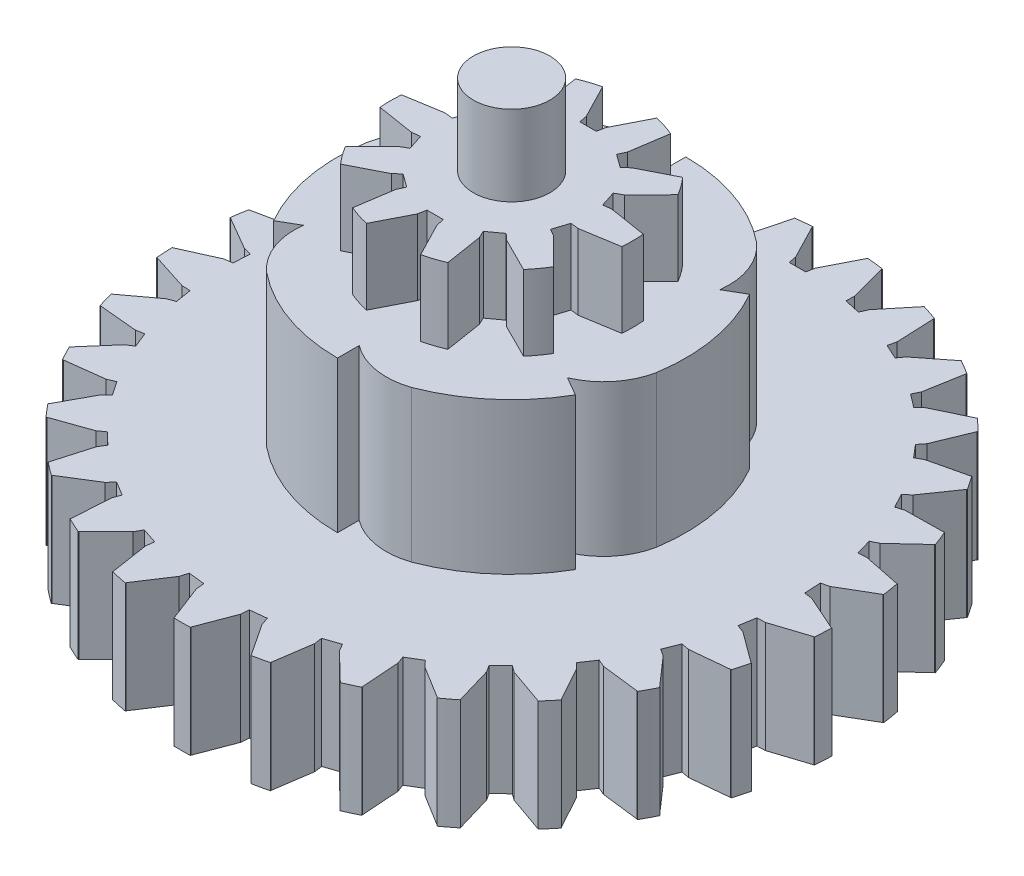
from build123d import *

# Parameters (mm, degrees)
SKETCH1_R           = 4.5085
BOSS_EXTRUDE1_DEPTH = 2.794
SKETCH2_R           = 1.4224
BOSS_EXTRUDE2_DEPTH = 2.9845
CUT_EXTRUDE1_DEPTH  = 3.794
SKETCH4_R           = 6.477
BOSS_EXTRUDE3_DEPTH = 5.6261
CUT_EXTRUDE2_DEPTH  = 6.6261
SKETCH6_R           = 12.26185
BOSS_EXTRUDE4_DEPTH = 4.1275
SKETCH7_R           = 1.4224
BOSS_EXTRUDE5_DEPTH = 3.302
CUT_EXTRUDE4_START  = -8.4295
CUT_EXTRUDE4_DEPTH  = 20.8341
CIRPATTERN3_COUNT   = 29


with BuildPart() as part:
    # Sketch1 → Boss-Extrude1 (new body)
    with BuildSketch(Plane(origin=(0, 0, 0), x_dir=(1, 0, 0), z_dir=(0, 1, 0))):
        with Locations((-83.120700882, 52.732487656)):
            Circle(SKETCH1_R)
    extrude(amount=BOSS_EXTRUDE1_DEPTH)

    # Sketch2 → Boss-Extrude2 (add)
    with BuildSketch(Plane(origin=(0, 2.794, 0), x_dir=(1, 0, 0), z_dir=(0, 1, 0))):
        with Locations((-83.120700882, 52.732487656)):
            Circle(SKETCH2_R)
    extrude(amount=BOSS_EXTRUDE2_DEPTH)

    # Sketch3 → Cut-Extrude1 (cut, through all)
    with BuildSketch(Plane(origin=(0, 2.794, 0), x_dir=(1, 0, 0), z_dir=(0, 1, 0))):
        with BuildLine():
            Line((-84.673607873, 55.488015957), (-84.892824637, 56.878105782))
            ThreePointArc((-84.892824637, 56.878105782), (-85.774201932, 56.377416246), (-86.521443741, 55.692474186))
            Line((-86.521443741, 55.692474186), (-85.261813421, 55.05922157))
            Line((-85.261813421, 55.05922157), (-85.037775379, 54.852557602))
            Line((-85.037775379, 54.852557602), (-84.791186999, 55.031714547))
            Line((-84.791186999, 55.031714547), (-84.544598619, 55.210871492))
            Line((-84.544598619, 55.210871492), (-84.673607873, 55.488015957))
        make_face()
        with BuildLine():
            Line((-83.120700882, 57.240987656), (-83.120700882, 55.574488389))
            Line((-83.120700882, 55.574488389), (-82.815900882, 55.574488389))
            Line((-82.815900882, 55.574488389), (-82.757370131, 55.874532708))
            Line((-82.757370131, 55.874532708), (-82.11764592, 57.127991381))
            ThreePointArc((-82.11764592, 57.127991381), (-82.616001116, 57.212649528), (-83.120700882, 57.240987656))
        make_face()
        with BuildLine():
            Line((-83.425500882, 55.574488389), (-83.120700882, 55.574488389))
            Line((-83.120700882, 55.574488389), (-83.120700882, 57.240987656))
            ThreePointArc((-83.120700882, 57.240987656), (-83.629665614, 57.212167014), (-84.132123219, 57.126073561))
            Line((-84.132123219, 57.126073561), (-83.485277432, 55.873369308))
            Line((-83.485277432, 55.873369308), (-83.425500882, 55.574488389))
        make_face()
        with BuildLine():
            ThreePointArc((-79.725600106, 55.698943954), (-80.474144714, 56.382461998), (-81.356473741, 56.881472453))
            Line((-81.356473741, 56.881472453), (-81.569485593, 55.487807009))
            Line((-81.569485593, 55.487807009), (-81.696803144, 55.210871492))
            Line((-81.696803144, 55.210871492), (-81.450214764, 55.031714547))
            Line((-81.450214764, 55.031714547), (-81.203626384, 54.852557602))
            Line((-81.203626384, 54.852557602), (-80.979912387, 55.060895043))
            Line((-80.979912387, 55.060895043), (-79.725600106, 55.698943954))
        make_face()
        with BuildLine():
            ThreePointArc((-78.630367393, 53.136811048), (-78.834190876, 54.129772243), (-79.254699067, 55.052100171))
            Line((-79.254699067, 55.052100171), (-80.24620527, 54.049806368))
            Line((-80.24620527, 54.049806368), (-80.511985946, 53.900596207))
            Line((-80.511985946, 53.900596207), (-80.417797566, 53.610714181))
            Line((-80.417797566, 53.610714181), (-80.323609186, 53.320832154))
            Line((-80.323609186, 53.320832154), (-80.020163085, 53.357884896))
            Line((-80.020163085, 53.357884896), (-78.630367393, 53.136811048))
        make_face()
        with BuildLine():
            ThreePointArc((-79.250289452, 50.420240349), (-78.831538167, 51.343367268), (-78.629605686, 52.33671475))
            Line((-78.629605686, 52.33671475), (-80.02088457, 52.108634752))
            Line((-80.02088457, 52.108634752), (-80.323609186, 52.144143158))
            Line((-80.323609186, 52.144143158), (-80.417797566, 51.854261132))
            Line((-80.417797566, 51.854261132), (-80.511985946, 51.564379106))
            Line((-80.511985946, 51.564379106), (-80.244713838, 51.41599426))
            Line((-80.244713838, 51.41599426), (-79.250289452, 50.420240349))
        make_face()
        with BuildLine():
            ThreePointArc((-81.348577127, 48.58686953), (-80.467199832, 49.087559066), (-79.719958023, 49.772501126))
            Line((-79.719958023, 49.772501126), (-80.979588343, 50.405753742))
            Line((-80.979588343, 50.405753742), (-81.203626384, 50.612417711))
            Line((-81.203626384, 50.612417711), (-81.450214764, 50.433260766))
            Line((-81.450214764, 50.433260766), (-81.696803144, 50.254103821))
            Line((-81.696803144, 50.254103821), (-81.56779389, 49.976959356))
            Line((-81.56779389, 49.976959356), (-81.348577127, 48.58686953))
        make_face()
        with BuildLine():
            Line((-83.484031632, 49.590442605), (-84.123755844, 48.336983932))
            ThreePointArc((-84.123755844, 48.336983932), (-83.116408709, 48.223989699), (-82.109278545, 48.338901751))
            Line((-82.109278545, 48.338901751), (-82.756124332, 49.591606004))
            Line((-82.756124332, 49.591606004), (-82.815900882, 49.890486924))
            Line((-82.815900882, 49.890486924), (-83.120700882, 49.890486924))
            Line((-83.120700882, 49.890486924), (-83.425500882, 49.890486924))
            Line((-83.425500882, 49.890486924), (-83.484031632, 49.590442605))
        make_face()
        with BuildLine():
            Line((-85.261489377, 50.40408027), (-86.515801658, 49.766031358))
            ThreePointArc((-86.515801658, 49.766031358), (-85.76725705, 49.082513314), (-84.884928023, 48.583502859))
            Line((-84.884928023, 48.583502859), (-84.671916171, 49.977168303))
            Line((-84.671916171, 49.977168303), (-84.544598619, 50.254103821))
            Line((-84.544598619, 50.254103821), (-84.791186999, 50.433260766))
            Line((-84.791186999, 50.433260766), (-85.037775379, 50.612417711))
            Line((-85.037775379, 50.612417711), (-85.261489377, 50.40408027))
        make_face()
        with BuildLine():
            Line((-86.221238679, 52.107090416), (-87.611034371, 52.328164264))
            ThreePointArc((-87.611034371, 52.328164264), (-87.407210888, 51.335203069), (-86.986702696, 50.412875141))
            Line((-86.986702696, 50.412875141), (-85.995196494, 51.415168945))
            Line((-85.995196494, 51.415168945), (-85.729415818, 51.564379106))
            Line((-85.729415818, 51.564379106), (-85.823604198, 51.854261132))
            Line((-85.823604198, 51.854261132), (-85.917792578, 52.144143158))
            Line((-85.917792578, 52.144143158), (-86.221238679, 52.107090416))
        make_face()
        with BuildLine():
            Line((-85.996687926, 54.048981052), (-86.991112312, 55.044734964))
            ThreePointArc((-86.991112312, 55.044734964), (-87.409863597, 54.121608045), (-87.611796077, 53.128260563))
            Line((-87.611796077, 53.128260563), (-86.220517194, 53.35634056))
            Line((-86.220517194, 53.35634056), (-85.917792578, 53.320832154))
            Line((-85.917792578, 53.320832154), (-85.823604198, 53.610714181))
            Line((-85.823604198, 53.610714181), (-85.729415818, 53.900596207))
            Line((-85.729415818, 53.900596207), (-85.996687926, 54.048981052))
        make_face()
    extrude(amount=-CUT_EXTRUDE1_DEPTH, mode=Mode.SUBTRACT)

    # Sketch4 → Boss-Extrude3 (add)
    with BuildSketch(Plane.XZ):
        with Locations((-83.120700882, -52.732487656)):
            Circle(SKETCH4_R)
    extrude(amount=BOSS_EXTRUDE3_DEPTH)

    # Sketch5 → Cut-Extrude2 (cut, through all)
    with BuildSketch(Plane(origin=(0, 0, 0), x_dir=(1, 0, 0), z_dir=(0, 1, 0))):
        with BuildLine():
            Line((-83.120700882, 58.401482942), (-83.120700882, 59.209487656))
            ThreePointArc((-83.120700882, 59.209487656), (-84.304718474, 59.100346899), (-85.448833465, 58.776602784))
            ThreePointArc((-85.448833465, 58.776602784), (-84.238083312, 58.878780186), (-83.120700882, 58.401482942))
        make_face()
        with BuildLine():
            Line((-78.21120695, 55.566985299), (-77.511454342, 55.970987656))
            ThreePointArc((-77.511454342, 55.970987656), (-78.197981806, 56.941806591), (-79.05040993, 57.77076718))
            ThreePointArc((-79.05040993, 57.77076718), (-78.356546627, 56.773315492), (-78.21120695, 55.566985299))
        make_face()
        with BuildLine():
            Line((-78.21120695, 49.897990013), (-77.511454342, 49.493987656))
            ThreePointArc((-77.511454342, 49.493987656), (-77.013964213, 50.573947348), (-76.722277346, 51.726652053))
            ThreePointArc((-76.722277346, 51.726652053), (-77.239164197, 50.627022962), (-78.21120695, 49.897990013))
        make_face()
        with BuildLine():
            Line((-83.120700882, 47.06349237), (-83.120700882, 46.255487656))
            ThreePointArc((-83.120700882, 46.255487656), (-81.936683289, 46.364628413), (-80.792568299, 46.688372529))
            ThreePointArc((-80.792568299, 46.688372529), (-82.003318452, 46.586195126), (-83.120700882, 47.06349237))
        make_face()
        with BuildLine():
            Line((-88.030194814, 49.897990013), (-88.729947422, 49.493987656))
            ThreePointArc((-88.729947422, 49.493987656), (-88.043419958, 48.523168721), (-87.190991834, 47.694208132))
            ThreePointArc((-87.190991834, 47.694208132), (-87.884855137, 48.691659821), (-88.030194814, 49.897990013))
        make_face()
        with BuildLine():
            Line((-88.030194814, 55.566985299), (-88.729947422, 55.970987656))
            ThreePointArc((-88.729947422, 55.970987656), (-89.22743755, 54.891027964), (-89.519124417, 53.73832326))
            ThreePointArc((-89.519124417, 53.73832326), (-89.002237567, 54.837952351), (-88.030194814, 55.566985299))
        make_face()
    extrude(amount=-CUT_EXTRUDE2_DEPTH, mode=Mode.SUBTRACT)

    # Sketch6 → Boss-Extrude4 (add)
    with BuildSketch(Plane.XZ.offset(5.6261)):
        with Locations((-83.120700882, -52.732487656)):
            Circle(SKETCH6_R)
    extrude(amount=BOSS_EXTRUDE4_DEPTH)

    # Sketch7 → Boss-Extrude5 (add)
    with BuildSketch(Plane.XZ.offset(9.7536)):
        with Locations((-83.120700882, -52.732487656)):
            Circle(SKETCH7_R)
    extrude(amount=BOSS_EXTRUDE5_DEPTH)

    # Sketch11 → Cut-Extrude4 (cut)
    with BuildSketch(Plane(origin=(0, -5.6261, 0), x_dir=(1, 0, 0), z_dir=(0, 1, 0)).offset(CUT_EXTRUDE4_START)):
        Polygon((-83.120700882, 63.360395178), (-82.815900882, 63.360395178), (-82.757370131, 63.660439497), (-82.109868573, 64.929136899), (-82.059835138, 65.691964937), (-84.203411341, 65.691964937), (-84.140686365, 64.92856404), (-83.485277432, 63.659276098), (-83.425500882, 63.360395178), align=None)
    cut_extrude4 = extrude(amount=CUT_EXTRUDE4_DEPTH, mode=Mode.SUBTRACT)

    # CirPattern3: Cut-Extrude4 ×29 about axis
    cirpattern3_axis = Axis((-83.120700882, 0, -52.732487656), (0, 1, 0))
    for i in range(1, CIRPATTERN3_COUNT):
        add(cut_extrude4.rotate(cirpattern3_axis, i * 360 / CIRPATTERN3_COUNT), mode=Mode.SUBTRACT)


solid = part.part
